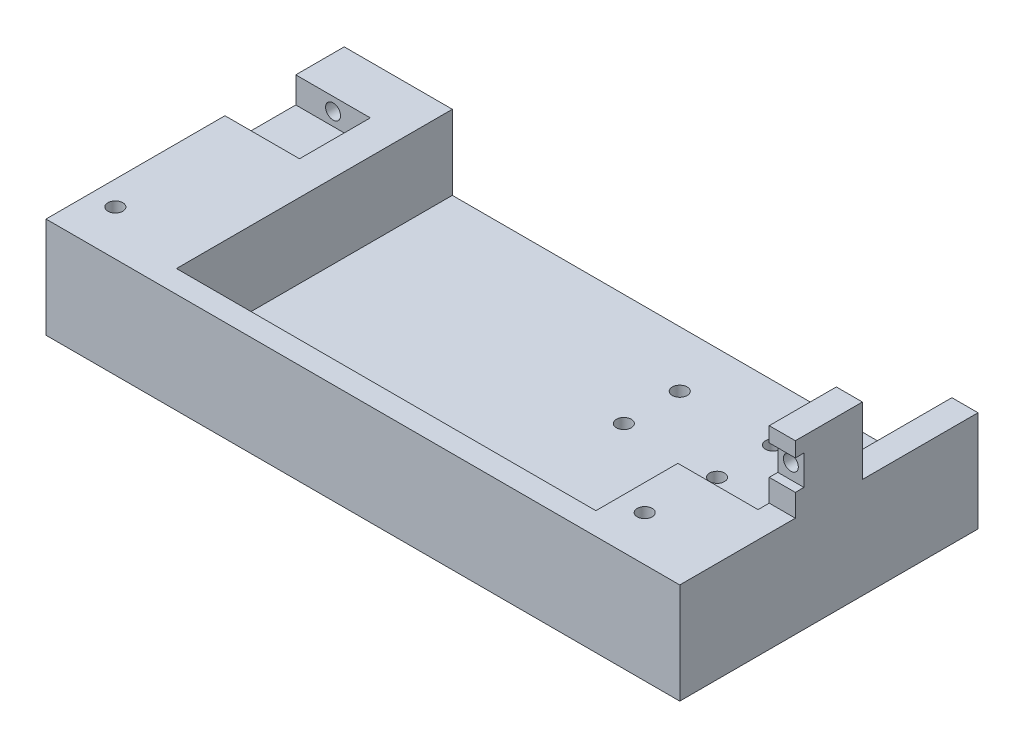
from build123d import *

# Parameters (mm, degrees)
SKETCH1_W               = 170
SKETCH1_H               = 80
BOSS_EXTRUDE1_DEPTH     = 7
SKETCH2_W               = 7
SKETCH2_H               = 18
BOSS_EXTRUDE2_DEPTH     = 18
SKETCH3_R               = 2
CUT_EXTRUDE1_DEPTH      = 20
SKETCH4_W               = 7
SKETCH4_H               = 8
CUT_EXTRUDE2_DEPTH      = 2.3
SKETCH6_W               = 20
SKETCH6_H               = 19
CUT_EXTRUDE4_DEPTH      = 11
SKETCH7_R               = 2
CUT_EXTRUDE5_DEPTH      = 25
CUT_EXTRUDE6_START      = 25
SKETCH7_2_R             = 2
CUT_EXTRUDE6_DEPTH      = 25
SKETCH8_W               = 170
SKETCH8_H               = 80
BOSS_EXTRUDE3_DEPTH     = 20
SKETCH9_W               = 134
SKETCH9_H               = 80
CUT_EXTRUDE7_DEPTH      = 20
SKETCH12_W              = 134
SKETCH12_H              = 28
BOSS_EXTRUDE4_DEPTH     = 20
CUT_EXTRUDE9_DEPTH      = 109.531695155
CUT_EXTRUDE9_DEPTH_BACK = 109.531695155
SKETCH10_R              = 2
SKETCH13_W              = 112.5
SKETCH13_H              = 22
CUT_EXTRUDE10_DEPTH     = 20
SKETCH14_R              = 2
CUT_EXTRUDE11_DEPTH     = 10


with BuildPart() as part:
    # Sketch1 → Boss-Extrude1 (new body)
    with BuildSketch(Plane(origin=(0, 0, 0), x_dir=(1, 0, 0), z_dir=(0, 1, 0))):
        with Locations((5.170316302, -0.291970803)):
            Rectangle(SKETCH1_W, SKETCH1_H)
    extrude(amount=BOSS_EXTRUDE1_DEPTH)

    # Sketch2 → Boss-Extrude2 (add)
    with BuildSketch(Plane(origin=(0, 7, 0), x_dir=(1, 0, 0), z_dir=(0, 1, 0))):
        with Locations((-76.329683698, -0.291970803)):
            Rectangle(SKETCH2_W, SKETCH2_H)
    extrude(amount=BOSS_EXTRUDE2_DEPTH)

    # Sketch3 → Cut-Extrude1 (cut)
    with BuildSketch(Plane(origin=(0, 0, -8.708029197), x_dir=(-1, 0, 0), z_dir=(0, 0, -1))):
        with Locations((76.329683698, 17)):
            Circle(SKETCH3_R)
    extrude(amount=-CUT_EXTRUDE1_DEPTH, mode=Mode.SUBTRACT)

    # Sketch4 → Cut-Extrude2 (cut)
    with BuildSketch(Plane.XY.offset(9.291970803)):
        with Locations((-76.329683698, 17)):
            Rectangle(SKETCH4_W, SKETCH4_H)
    extrude(amount=-CUT_EXTRUDE2_DEPTH, mode=Mode.SUBTRACT)

    # Sketch6 → Cut-Extrude4 (cut)
    with BuildSketch(Plane(origin=(0, 7, 0), x_dir=(1, 0, 0), z_dir=(0, 1, 0))):
        with Locations((80.170316302, 17.208029197)):
            Rectangle(SKETCH6_W, SKETCH6_H)
    extrude(amount=-CUT_EXTRUDE4_DEPTH, mode=Mode.SUBTRACT)

    # Sketch7 → Cut-Extrude5 (cut)
    with BuildSketch(Plane.XY.offset(-26.708029197)):
        with Locations((80.170316302, 3.5)):
            Circle(SKETCH7_R)
    extrude(amount=-CUT_EXTRUDE5_DEPTH, mode=Mode.SUBTRACT)

    # Sketch7_2 → Cut-Extrude6 (cut)
    with BuildSketch(Plane.XY.offset(-26.708029197).offset(CUT_EXTRUDE6_START)):
        with Locations((80.170316302, 3.5)):
            Circle(SKETCH7_2_R)
    extrude(amount=-CUT_EXTRUDE6_DEPTH, mode=Mode.SUBTRACT)

    # Sketch8 → Boss-Extrude3 (add)
    with BuildSketch(Plane.XZ):
        with Locations((5.170316302, 0.291970803)):
            Rectangle(SKETCH8_W, SKETCH8_H)
    extrude(amount=BOSS_EXTRUDE3_DEPTH)

    # Sketch9 → Cut-Extrude7 (cut)
    with BuildSketch(Plane(origin=(0, 7, 0), x_dir=(1, 0, 0), z_dir=(0, 1, 0))):
        with Locations((-5.829683698, -0.291970803)):
            Rectangle(SKETCH9_W, SKETCH9_H)
    extrude(amount=-CUT_EXTRUDE7_DEPTH, mode=Mode.SUBTRACT)

    # Sketch12 → Boss-Extrude4 (add)
    with BuildSketch(Plane(origin=(0, -13, 0), x_dir=(1, 0, 0), z_dir=(0, 1, 0))):
        with Locations((-5.829683698, -26.291970803)):
            Rectangle(SKETCH12_W, SKETCH12_H)
    extrude(amount=BOSS_EXTRUDE4_DEPTH)

    # Sketch10 → Cut-Extrude9 (cut, two sides: drawn at the far end of the back side and taken through both)
    with BuildSketch(Plane.XZ.offset(20).offset(-CUT_EXTRUDE9_DEPTH_BACK)):
        with Locations((83.670316302, 28.191970803)):
            Circle(SKETCH10_R)
        with Locations((-58.329683698, 28.191970803)):
            Circle(SKETCH10_R)
    extrude(amount=CUT_EXTRUDE9_DEPTH + CUT_EXTRUDE9_DEPTH_BACK, mode=Mode.SUBTRACT)

    # Sketch13 → Cut-Extrude10 (cut)
    with BuildSketch(Plane(origin=(0, 7, 0), x_dir=(1, 0, 0), z_dir=(0, 1, 0))):
        with Locations((4.920316302, -23.291970803)):
            Rectangle(SKETCH13_W, SKETCH13_H)
    extrude(amount=-CUT_EXTRUDE10_DEPTH, mode=Mode.SUBTRACT)

    # Sketch14 → Cut-Extrude11 (cut)
    with BuildSketch(Plane(origin=(0, -13, 0), x_dir=(1, 0, 0), z_dir=(0, 1, 0))):
        with Locations((-39.829683698, 24.708029197)):
            Circle(SKETCH14_R)
        with Locations((-39.829683698, 9.708029197)):
            Circle(SKETCH14_R)
        with Locations((-14.829683698, 9.708029197)):
            Circle(SKETCH14_R)
        with Locations((-14.829683698, 24.708029197)):
            Circle(SKETCH14_R)
    extrude(amount=-CUT_EXTRUDE11_DEPTH, mode=Mode.SUBTRACT)


with BuildPart() as body_2:
    # Mirror2: mirrored copy
    add(part.part.mirror(Plane(origin=(90.170316302, 7, -39.708029197), x_dir=(0, 0, 1), z_dir=(-1, 0, 0))))


solid = body_2.part
